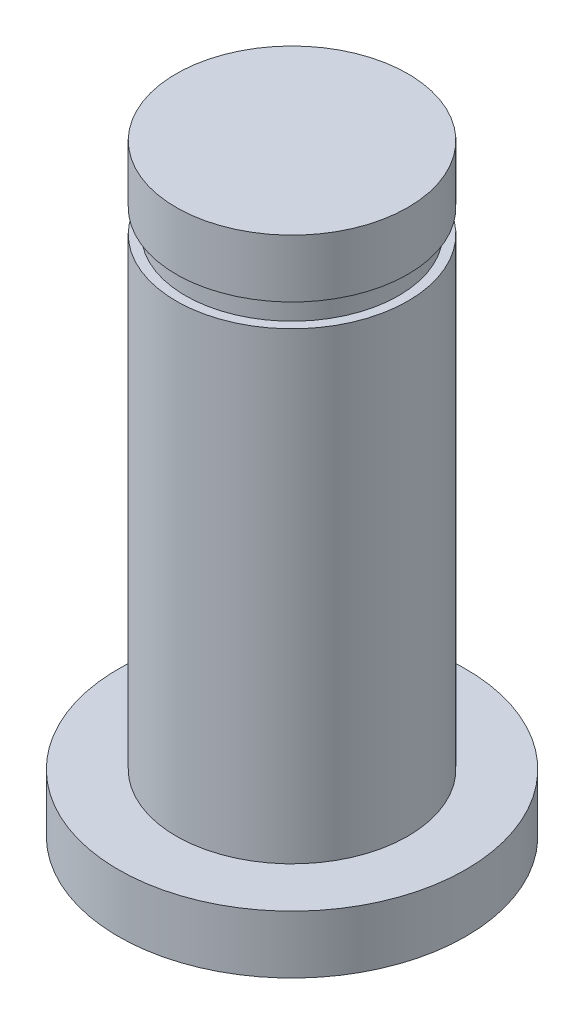
from build123d import *


with BuildPart() as part:
    # Sketch1 → Revolve1 (revolve)
    with BuildSketch(Plane.XY):
        Polygon((0, 0), (-3.175, 0), (-3.175, -1.5875), (-2.921, -1.5875), (-2.921, -2.2225), (-3.175, -2.2225), (-3.175, -14.9225), (-4.7625, -14.9225), (-4.7625, -16.51), (0, -16.51), align=None)
    revolve(axis=Axis((0, -16.51, 0), (0, 1, 0)))


solid = part.part
